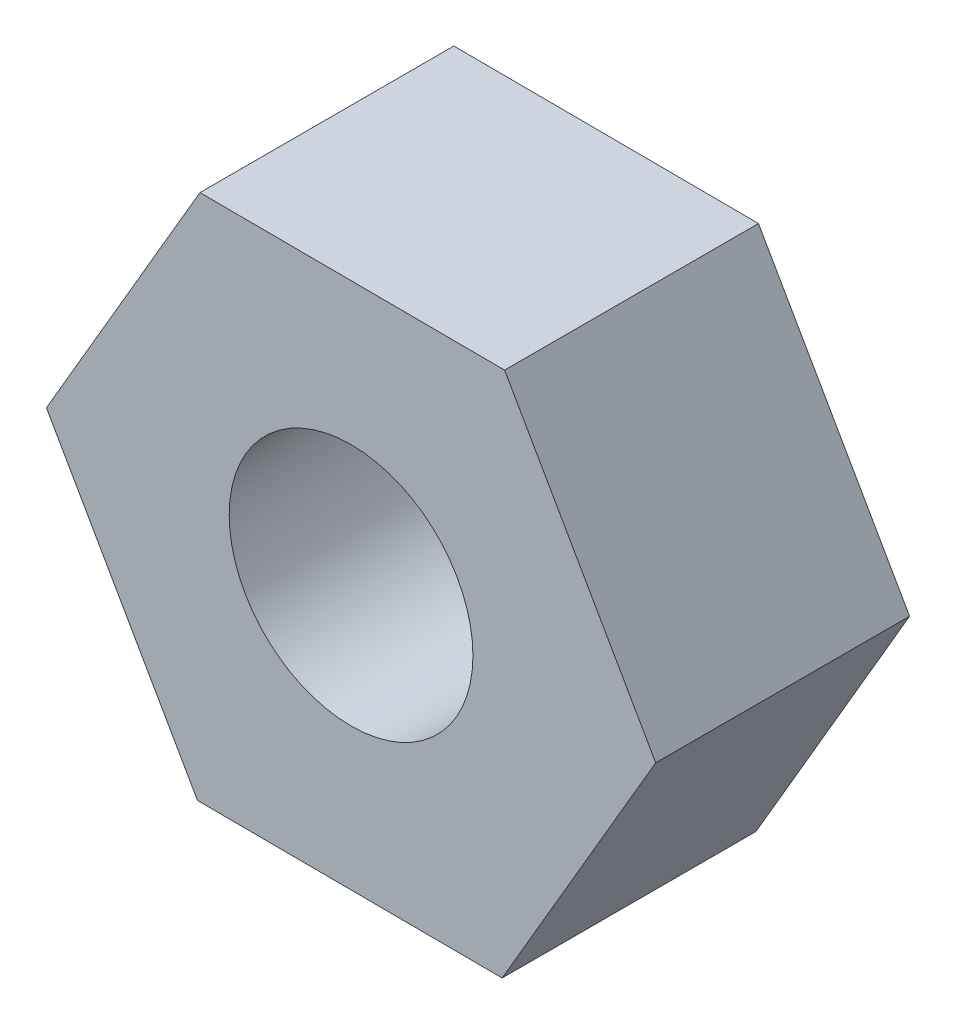
from build123d import *

# Parameters (mm, degrees)
SKETCH_1_R      = 2.4
EXTRUDE_1_DEPTH = 5


with BuildPart() as part:
    # 草图1 → 凸台-拉伸1 (new body)
    with BuildSketch(Plane.XY):
        Polygon((-2.975748094, 5.210154267), (-6, 0.028003689), (-3.024251906, -5.182150578), (2.975748094, -5.210154267), (6, -0.028003689), (3.024251906, 5.182150578), align=None)
        Circle(SKETCH_1_R, mode=Mode.SUBTRACT)
    extrude(amount=EXTRUDE_1_DEPTH)


solid = part.part
